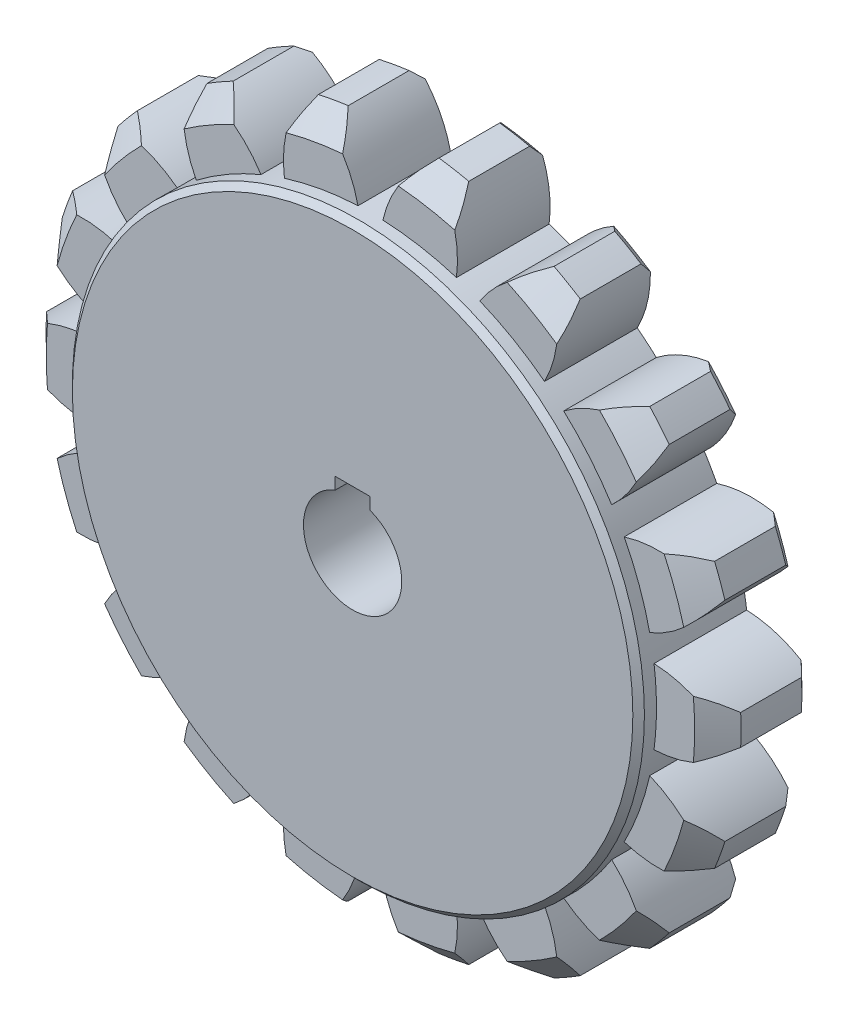
from build123d import *

# Parameters (mm, degrees)
SKETCH1_R               = 30
GEAR_BLANK_DEPTH        = 4
FRONT_GEAR_CHAMFER_SIZE = 2
REAR_GEAR_CHAMFER_SIZE  = 0.75
TOOTH_CUT_DEPTH         = 4
TOOTH_COPIES_COUNT      = 18
SKETCH3_R               = 24.7
BOSS_EXTRUDE1_DEPTH     = 1.54
CHAMFER1_SIZE           = 0.5
CUT_EXTRUDE1_DEPTH      = 10


with BuildPart() as part:
    # Sketch1 → Gear Blank (new body, symmetric)
    with BuildSketch(Plane.XY):
        Circle(SKETCH1_R)
    extrude(amount=GEAR_BLANK_DEPTH, both=True)

    # Front Gear Chamfer
    front_gear_chamfer_edges = [part.edges().sort_by_distance(p)[0] for p in [
        (-30, 0, 4),
    ]]
    chamfer(front_gear_chamfer_edges, length=FRONT_GEAR_CHAMFER_SIZE)

    # Rear Gear Chamfer
    rear_gear_chamfer_edges = [part.edges().sort_by_distance(p)[0] for p in [
        (-30, 0, -4),
    ]]
    chamfer(rear_gear_chamfer_edges, length=REAR_GEAR_CHAMFER_SIZE)

    # Sketch2 → Tooth Cut (cut, symmetric)
    with BuildSketch(Plane.XY):
        with BuildLine():
            ThreePointArc((3.915772007, 29.743347653), (-1.3878e-05, 30), (-3.915799526, 29.74334403))
            ThreePointArc((-3.915799526, 29.74334403), (-2.12067037, 27.420511224), (-1.077410283, 24.676490575))
            ThreePointArc((-1.077410283, 24.676490575), (-1.1426e-05, 24.7), (1.077387453, 24.676491571))
            ThreePointArc((1.077387453, 24.676491571), (2.120645001, 27.420513186), (3.915772007, 29.743347653))
        make_face()
    tooth_cut = extrude(amount=TOOTH_CUT_DEPTH, both=True, mode=Mode.SUBTRACT)

    # Tooth Copies: Tooth Cut ×18 about axis
    tooth_copies_axis = Axis((0, 0, 0), (0, 0, 1))
    for i in range(1, TOOTH_COPIES_COUNT):
        add(tooth_cut.rotate(tooth_copies_axis, i * 360 / TOOTH_COPIES_COUNT), mode=Mode.SUBTRACT)

    # Sketch3 → Boss-Extrude1 (add)
    with BuildSketch(Plane.XY.offset(4)):
        Circle(SKETCH3_R)
    extrude(amount=BOSS_EXTRUDE1_DEPTH)

    # Chamfer1
    chamfer1_edges = [part.edges().sort_by_distance(p)[0] for p in [
        (-24.7, 0, 5.54),
    ]]
    chamfer(chamfer1_edges, length=CHAMFER1_SIZE)

    # Sketch4 → Cut-Extrude1 (cut)
    with BuildSketch(Plane(origin=(0, 0, -4), x_dir=(-1, 0, 0), z_dir=(0, 0, -1))):
        with BuildLine():
            Line((0, 5), (-1.5, 5))
            Line((-1.5, 5), (-1.5, 3.968626967))
            ThreePointArc((-1.5, 3.968626967), (0, -4.242640687), (1.5, 3.968626967))
            Line((1.5, 3.968626967), (1.5, 5))
            Line((1.5, 5), (0, 5))
        make_face()
    extrude(amount=-CUT_EXTRUDE1_DEPTH, mode=Mode.SUBTRACT)


solid = part.part
